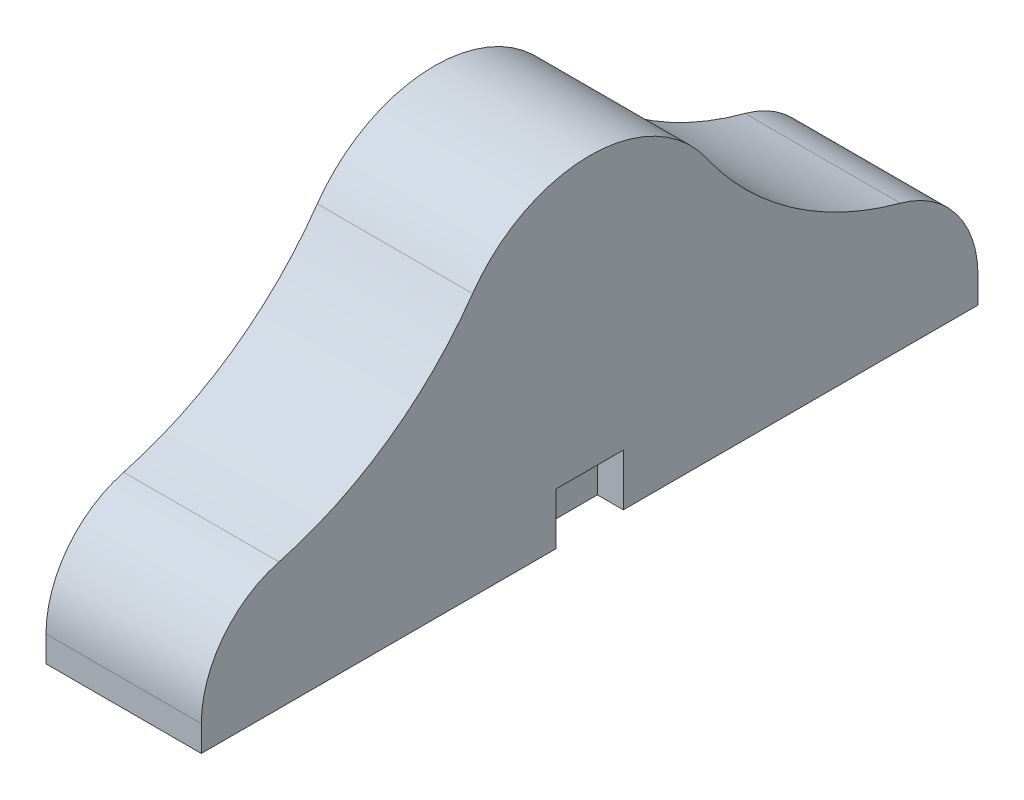
from build123d import *

# Parameters (mm, degrees)
SKETCH1_W           = 5.2
SKETCH1_H           = 2
BOSS_EXTRUDE1_DEPTH = 10
BOSS_EXTRUDE2_DEPTH = 2


with BuildPart() as part:
    # Sketch1 → Boss-Extrude1 (new body)
    with BuildSketch(Plane(origin=(0, 0, 0), x_dir=(0, 0, -1), z_dir=(1, 0, 0))):
        with BuildLine():
            Line((0, 0), (60, 0))
            Line((60, 0), (60, 2))
            ThreePointArc((60, 2), (58.327156209, 6.928038895), (54, 9.819352237))
            ThreePointArc((54, 9.819352237), (45.597676291, 13.737420129), (39.042132847, 20.292963573))
            ThreePointArc((39.042132847, 20.292963573), (30, 25), (20.957867153, 20.292963573))
            ThreePointArc((20.957867153, 20.292963573), (14.402323709, 13.737420129), (6, 9.819352237))
            ThreePointArc((6, 9.819352237), (1.672843791, 6.928038895), (0, 2))
            Line((0, 2), (0, 0))
        make_face()
        with Locations((30, 3)):
            Rectangle(SKETCH1_W, SKETCH1_H, mode=Mode.SUBTRACT)
    extrude(amount=-BOSS_EXTRUDE1_DEPTH)

    # Sketch2 → Boss-Extrude2 (add)
    with BuildSketch(Plane(origin=(0, 0, 0), x_dir=(0, 0, -1), z_dir=(1, 0, 0))):
        with BuildLine():
            Line((0, 0), (27.4, 0))
            Line((27.4, 0), (27.4, 4))
            Line((27.4, 4), (32.6, 4))
            Line((32.6, 4), (32.6, 0))
            Line((32.6, 0), (60, 0))
            Line((60, 0), (60, 2))
            ThreePointArc((60, 2), (58.327156209, 6.928038895), (54, 9.819352237))
            ThreePointArc((54, 9.819352237), (45.597676291, 13.737420129), (39.042132847, 20.292963573))
            ThreePointArc((39.042132847, 20.292963573), (30, 25), (20.957867153, 20.292963573))
            ThreePointArc((20.957867153, 20.292963573), (14.402323709, 13.737420129), (6, 9.819352237))
            ThreePointArc((6, 9.819352237), (1.672843791, 6.928038895), (0, 2))
            Line((0, 2), (0, 0))
        make_face()
    extrude(amount=BOSS_EXTRUDE2_DEPTH)


solid = part.part
